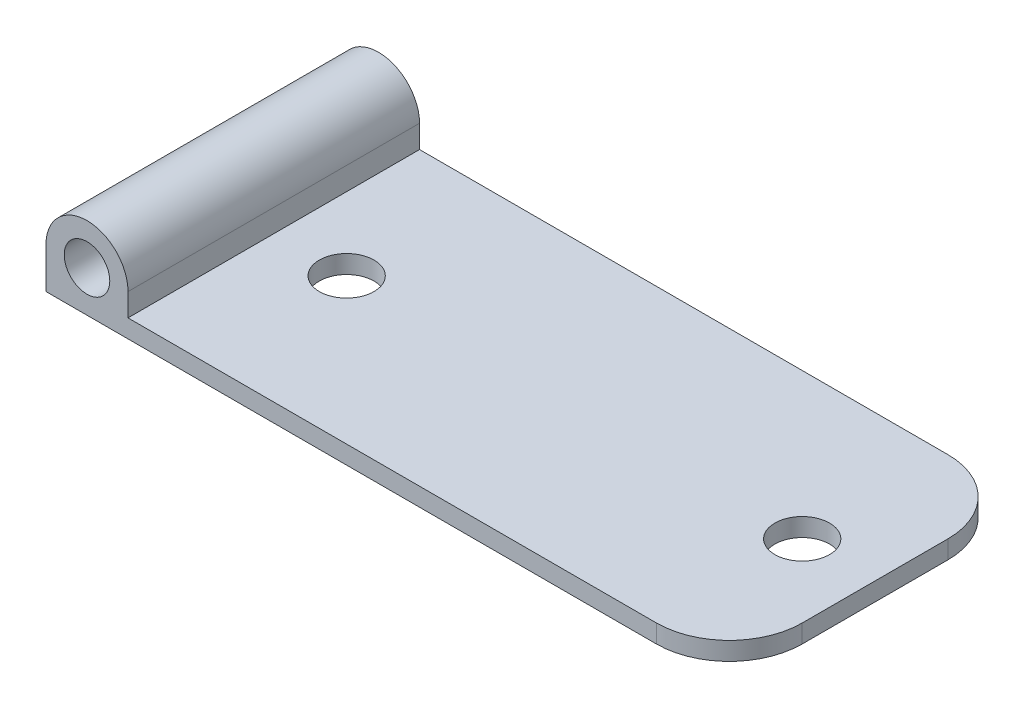
from build123d import *

# Parameters (mm, degrees)
SKETCH1_R           = 3.96875
BOSS_EXTRUDE1_DEPTH = 50.8
SKETCH6_R           = 4.7625
CUT_EXTRUDE3_DEPTH  = 12.7
FILLET2_R           = 12.7


with BuildPart() as part:
    # Sketch1 → Boss-Extrude1 (new body)
    with BuildSketch(Plane.XY):
        with BuildLine():
            ThreePointArc((7.14375, 0), (0, 7.14375), (-7.14375, 0))
            Line((-7.14375, 0), (-7.14375, -7.14375))
            Line((-7.14375, -7.14375), (111.91875, -7.14375))
            Line((111.91875, -7.14375), (111.91875, -3.96875))
            Line((111.91875, -3.96875), (7.14375, -3.96875))
            Line((7.14375, -3.96875), (7.14375, 0))
        make_face()
        Circle(SKETCH1_R, mode=Mode.SUBTRACT)
    extrude(amount=BOSS_EXTRUDE1_DEPTH)

    # Sketch6 → Cut-Extrude3 (cut)
    with BuildSketch(Plane(origin=(0, -3.96875, 0), x_dir=(1, 0, 0), z_dir=(0, 1, 0))):
        with Locations((19.84375, -25.4)):
            Circle(SKETCH6_R)
        with Locations((99.21875, -25.4)):
            Circle(SKETCH6_R)
    extrude(amount=-CUT_EXTRUDE3_DEPTH, mode=Mode.SUBTRACT)

    # Fillet2
    fillet2_edges = [part.edges().sort_by_distance(p)[0] for p in [
        (111.91875, -5.55625, 0),
        (111.91875, -5.55625, 50.8),
    ]]
    fillet(fillet2_edges, radius=FILLET2_R)


solid = part.part
